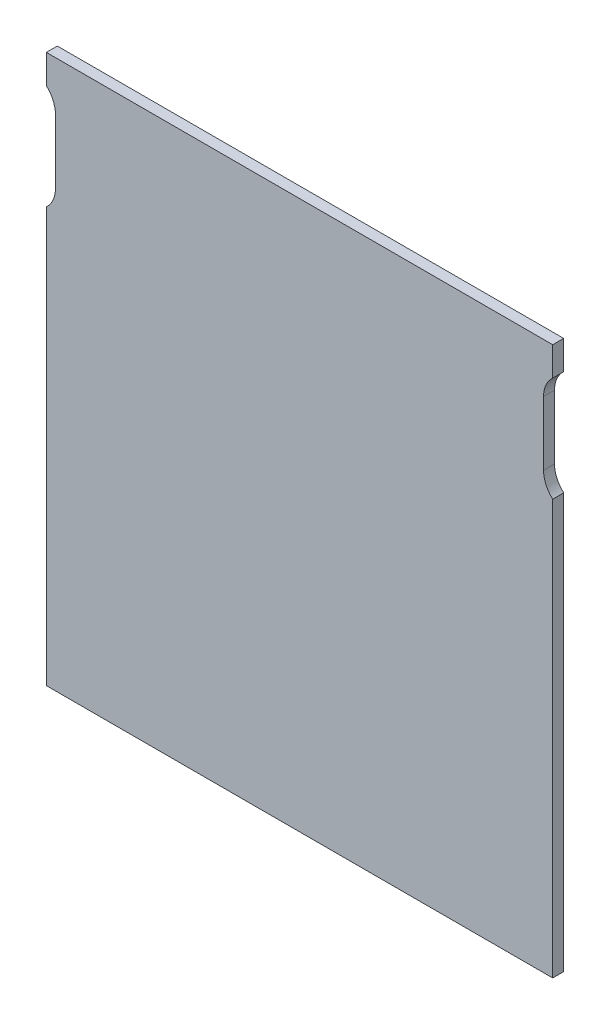
from build123d import *

# Parameters (mm, degrees)
SKETCH1_W           = 277
SKETCH1_H           = 300
BOSS_EXTRUDE1_DEPTH = 6
BOSS_EXTRUDE2_DEPTH = 7
BOSS_EXTRUDE3_DEPTH = 5
CUT_EXTRUDE1_DEPTH  = 19


with BuildPart() as part:
    # Sketch1 → Boss-Extrude1 (new body)
    with BuildSketch(Plane.XY):
        Rectangle(SKETCH1_W, SKETCH1_H)
    extrude(amount=BOSS_EXTRUDE1_DEPTH)

    # Sketch3 → Boss-Extrude2 (add)
    with BuildSketch(Plane(origin=(0, 0, 0), x_dir=(-1, 0, 0), z_dir=(0, 0, -1))):
        Polygon((-103.5, -130), (-34.217967697, -140), (-32.789396269, -130.102566814), (-102.071428571, -120.102566814), align=None)
    boss_extrude2 = extrude(amount=BOSS_EXTRUDE2_DEPTH)

    # Sketch4 → Boss-Extrude3 (add)
    with BuildSketch(Plane(origin=(0, 0, -7), x_dir=(-1, 0, 0), z_dir=(0, 0, -1))):
        Polygon((-102.071428571, -120.102566814), (-32.789396269, -130.102566814), (-34.932253412, -144.948716593), (-104.214285714, -134.948716593), align=None)
    boss_extrude3 = extrude(amount=BOSS_EXTRUDE3_DEPTH)

    # Sketch2 → Cut-Extrude1 (cut, through all)
    with BuildSketch(Plane.XY.offset(6)):
        with BuildLine():
            Line((133.5, 123), (133.5, 88))
            ThreePointArc((133.5, 88), (148.5, 73), (163.5, 88))
            Line((163.5, 88), (163.5, 123))
            ThreePointArc((163.5, 123), (148.5, 138), (133.5, 123))
        make_face()
    cut_extrude1 = extrude(amount=-CUT_EXTRUDE1_DEPTH, mode=Mode.SUBTRACT)

    # Mirror1: Boss-Extrude2, Boss-Extrude3, Cut-Extrude1 across plane
    add(boss_extrude2.mirror(Plane(origin=(0, 0, 0), x_dir=(0, 0, 1), z_dir=(1, 0, 0))))
    add(boss_extrude3.mirror(Plane(origin=(0, 0, 0), x_dir=(0, 0, 1), z_dir=(1, 0, 0))))
    add(cut_extrude1.mirror(Plane(origin=(0, 0, 0), x_dir=(0, 0, 1), z_dir=(1, 0, 0))), mode=Mode.SUBTRACT)


solid = part.part
